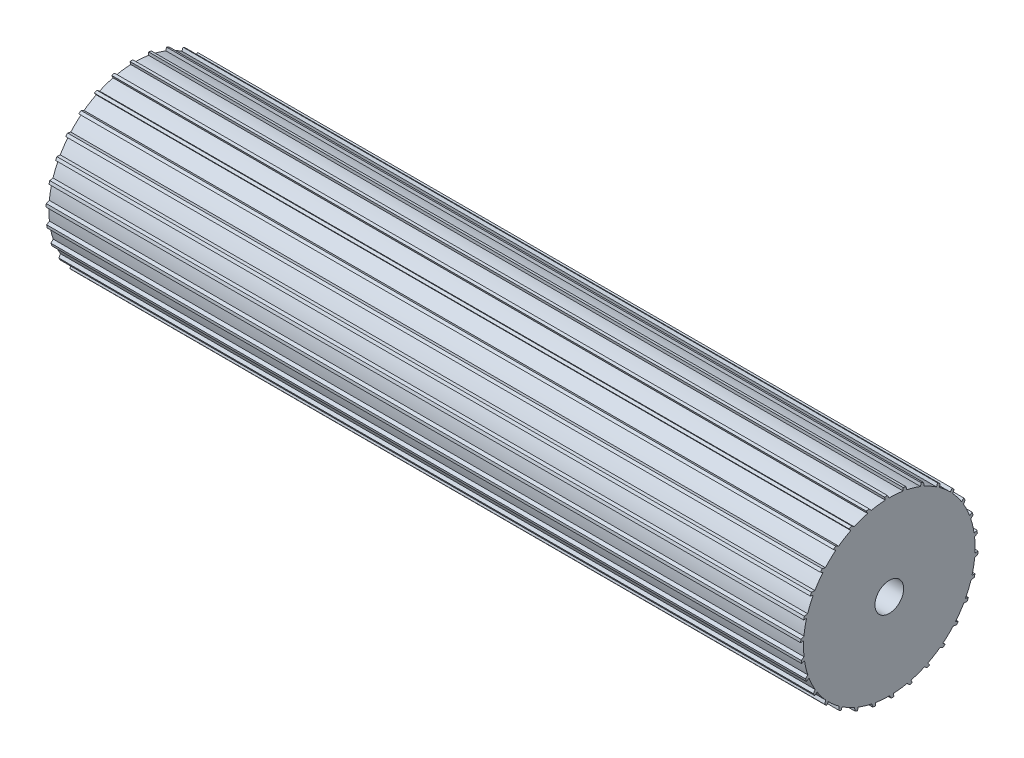
from build123d import *

# Parameters (mm, degrees)
Y_KSEKLIK_EKSTR_ZYON1_DEPTH = 210
IZIM5_R                     = 1.5
KES_EKSTR_ZYON1_DEPTH       = 35
KES_EKSTR_ZYON1_DEPTH_BACK  = 10
IZIM6_R                     = 1.5
KES_EKSTR_ZYON2_DEPTH       = 67
KES_EKSTR_ZYON2_DEPTH_BACK  = 10
IZIM7_R                     = 3.995
KES_EKSTR_ZYON3_DEPTH       = 310


with BuildPart() as part:
    # Çizim1 → Döndür2 (revolve)
    with BuildSketch(Plane.XY):
        Polygon((-74.631401138, 0), (135.368598862, 0), (135.368598862, -20), (165.368598862, -20), (165.368598862, -23.875), (-104.631401138, -23.875), (-104.631401138, -20), (-74.631401138, -20), align=None)
    revolve(axis=Axis((165.368598862, -23.875, 0), (-1, 0, 0)))

    # Çizim2 → Yükseklik-Ekstrüzyon1 (add)
    with BuildSketch(Plane.ZY.offset(74.631401138)):
        Polygon((-0.239858288, -0.577100131), (0.510254288, 0.807723086), (1.309824836, 0.807723086), (0.910039562, -0.783175015), align=None)
        Polygon((5.691213391, -1.476994658), (4.609288945, -1.036345799), (5.630930698, 0.162258534), (6.413028712, -0.003981531), align=None)
        Polygon((10.223653885, -3.149714613), (9.256988134, -2.493750248), (10.505508417, -1.533749559), (11.235952459, -1.8589642), align=None)
        Polygon((14.309271646, -5.72822899), (13.500112521, -4.885617909), (14.920945007, -4.206177502), (15.567811168, -4.676153278), align=None)
        Polygon((17.769505572, -9.099844337), (17.15321721, -8.107412689), (18.684264701, -7.738227369), (19.219281827, -8.332424084), align=None)
        Polygon((20.453126838, -13.117204887), (20.056643997, -12.018326695), (21.630992371, -11.975531633), (22.030777645, -12.66798004), align=None)
        Polygon((22.242848315, -17.604732704), (22.083499199, -16.44743422), (23.632341877, -16.732899765), (23.879422765, -17.493336545), align=None)
        Polygon((23.060450589, -22.36630129), (23.145199517, -21.20116201), (24.600844643, -21.802411948), (24.684422523, -22.597602365), align=None)
        Polygon((22.870200515, -27.19380725), (23.195343554, -26.071749352), (24.494172449, -26.962506175), (24.410594569, -27.757696592), align=None)
        Polygon((21.680412935, -31.876265407), (22.231739773, -30.846328205), (23.316987384, -31.987661567), (23.069906497, -32.748098346), align=None)
        Polygon((19.543087276, -36.209029872), (20.296502285, -35.316226564), (21.120738083, -36.658254719), (20.720952809, -37.350703125), align=None)
        Polygon((16.551634925, -40.002738046), (17.474210253, -39.286088421), (18.001411179, -40.770158299), (17.466394053, -41.364355014), align=None)
        Polygon((12.836796703, -43.091586678), (13.888211383, -42.582411763), (14.095336226, -44.143662389), (13.448470064, -44.613638165), align=None)
        Polygon((8.560928869, -45.34057826), (9.695231033, -45.061131443), (9.573227443, -46.631328673), (8.842783401, -46.956543314), align=None)
        Polygon((3.910907362, -46.65142107), (5.078522563, -46.613915516), (4.632722683, -48.124434198), (3.85062467, -48.290674262), align=None)
        Polygon((-0.910039562, -46.966824985), (0.239858288, -47.172899869), (-0.510254288, -48.557723086), (-1.309824836, -48.557723086), align=None)
        Polygon((-5.691213391, -46.273005342), (-4.609288945, -46.713654201), (-5.630930698, -47.912258534), (-6.413028712, -47.746018469), align=None)
        Polygon((-10.223653885, -44.600285387), (-9.256988134, -45.256249752), (-10.505508417, -46.216250441), (-11.235952459, -45.8910358), align=None)
        Polygon((-14.309271646, -42.02177101), (-13.500112521, -42.864382091), (-14.920945007, -43.543822498), (-15.567811168, -43.073846722), align=None)
        Polygon((-17.769505572, -38.650155663), (-17.15321721, -39.642587311), (-18.684264701, -40.011772631), (-19.219281827, -39.417575916), align=None)
        Polygon((-20.453126838, -34.632795113), (-20.056643997, -35.731673305), (-21.630992371, -35.774468367), (-22.030777645, -35.08201996), align=None)
        Polygon((-22.242848315, -30.145267296), (-22.083499199, -31.30256578), (-23.632341877, -31.017100235), (-23.879422765, -30.256663455), align=None)
        Polygon((-23.060450589, -25.38369871), (-23.145199517, -26.54883799), (-24.600844643, -25.947588052), (-24.684422523, -25.152397635), align=None)
        Polygon((-22.870200515, -20.55619275), (-23.195343554, -21.678250648), (-24.494172449, -20.787493825), (-24.410594569, -19.992303408), align=None)
        Polygon((-21.680412935, -15.873734593), (-22.231739773, -16.903671795), (-23.316987384, -15.762338433), (-23.069906497, -15.001901654), align=None)
        Polygon((-19.543087276, -11.540970128), (-20.296502285, -12.433773436), (-21.120738083, -11.091745281), (-20.720952809, -10.399296875), align=None)
        Polygon((-16.551634925, -7.747261954), (-17.474210253, -8.463911579), (-18.001411179, -6.979841701), (-17.466394053, -6.385644986), align=None)
        Polygon((-12.836796703, -4.658413322), (-13.888211383, -5.167588237), (-14.095336226, -3.606337611), (-13.448470064, -3.136361835), align=None)
        Polygon((-8.560928869, -2.40942174), (-9.695231033, -2.688868557), (-9.573227443, -1.118671327), (-8.842783401, -0.793456686), align=None)
        Polygon((-3.910907362, -1.09857893), (-5.078522563, -1.136084484), (-4.632722683, 0.374434198), (-3.85062467, 0.540674262), align=None)
    extrude(amount=-Y_KSEKLIK_EKSTR_ZYON1_DEPTH)

    # Çizim5 → Kes-Ekstrüzyon1 (cut, two sides)
    with BuildSketch(Plane.XY) as kes_ekstr_zyon1_sk:
        with Locations((-101.631401138, -23.958656311)):
            Circle(IZIM5_R)
    extrude(amount=KES_EKSTR_ZYON1_DEPTH, mode=Mode.SUBTRACT)
    extrude(kes_ekstr_zyon1_sk.sketch, amount=-KES_EKSTR_ZYON1_DEPTH_BACK, mode=Mode.SUBTRACT)

    # Çizim6 → Kes-Ekstrüzyon2 (cut, two sides)
    with BuildSketch(Plane.XY) as kes_ekstr_zyon2_sk:
        with Locations((162.368598862, -23.875)):
            Circle(IZIM6_R)
    extrude(amount=KES_EKSTR_ZYON2_DEPTH, mode=Mode.SUBTRACT)
    extrude(kes_ekstr_zyon2_sk.sketch, amount=-KES_EKSTR_ZYON2_DEPTH_BACK, mode=Mode.SUBTRACT)

    # Çizim7 → Kes-Ekstrüzyon3 (cut)
    with BuildSketch(Plane(origin=(165.368598862, 0, 0), x_dir=(0, 0, -1), z_dir=(1, 0, 0))):
        with Locations((0, -23.875)):
            Circle(IZIM7_R)
    extrude(amount=-KES_EKSTR_ZYON3_DEPTH, mode=Mode.SUBTRACT)


solid = part.part
